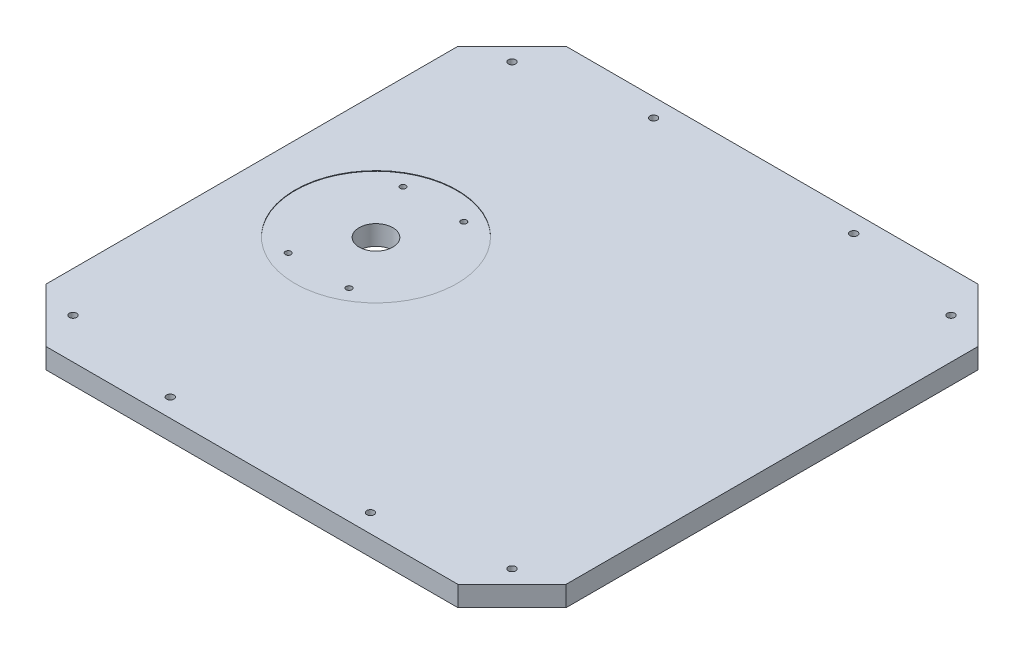
from build123d import *

# Parameters (mm, degrees)
BOSS_EXTRUDE1_DEPTH                = 9.525
F_8_32_TAPPED_HOLE1_D              = 3.4544
F_5_8_0_625_DIAMETER_HOLE1_D       = 15.875
F_6_32_TAPPED_HOLE1_D              = 2.7051
F_6_32_TAPPED_HOLE1_DEPTH          = 8.128
F_6_32_TAPPED_HOLE1_TIP            = 0.81269403
SKETCH8_R                          = 38.1
SKETCH8_R_2                        = 1.35255
SKETCH8_R_3                        = 7.9375
CUT_EXTRUDE1_DEPTH                 = 0.254
F_8_32_TAPPED_HOLE2_D              = 3.4544
F_5_16_0_3125_DIAMETER_HOLE1_D     = 7.9375
F_5_16_0_3125_DIAMETER_HOLE1_DEPTH = 5.08
F_5_16_0_3125_DIAMETER_HOLE1_TIP   = 2.384665582


with BuildPart() as part:
    # Sketch1 → Boss-Extrude1 (new body)
    with BuildSketch(Plane(origin=(0, 0, 0), x_dir=(1, 0, 0), z_dir=(0, 1, 0))):
        Polygon((-96.8375, 122.2375), (-122.2375, 96.8375), (-122.2375, -96.8375), (-96.8375, -122.2375), (96.8375, -122.2375), (122.2375, -96.8375), (122.2375, 96.8375), (96.8375, 122.2375), align=None)
    extrude(amount=BOSS_EXTRUDE1_DEPTH)

    # #8-32 Tapped Hole1 (through all)
    with Locations(Plane(origin=(0, 9.525, 0), x_dir=(1, 0, 0), z_dir=(0, 1, 0))):
        with Locations((-47.0535, 113.6015), (47.0535, 113.6015), (47.0535, -113.6015), (-47.0535, -113.6015)):
            Hole(F_8_32_TAPPED_HOLE1_D / 2)

    # 5/8 (0.625) Diameter Hole1 (through all)
    with Locations(Plane(origin=(0, 9.525, 0), x_dir=(1, 0, 0), z_dir=(0, 1, 0))):
        with Locations((-63.9445, 0)):
            Hole(F_5_8_0_625_DIAMETER_HOLE1_D / 2)

    # #6-32 Tapped Hole1
    with Locations(Plane(origin=(0, 9.525, 0), x_dir=(1, 0, 0), z_dir=(0, 1, 0))):
        with Locations((-78.232, -26.9875), (-49.657, -26.9875), (-49.657, 26.9875), (-78.232, 26.9875)):
            Hole(F_6_32_TAPPED_HOLE1_D / 2, depth=F_6_32_TAPPED_HOLE1_DEPTH)
            with Locations((0, 0, -(F_6_32_TAPPED_HOLE1_DEPTH + F_6_32_TAPPED_HOLE1_TIP / 2))):  # 118° drill point
                Cone(0, F_6_32_TAPPED_HOLE1_D / 2, F_6_32_TAPPED_HOLE1_TIP, mode=Mode.SUBTRACT)

    # Sketch8 → Cut-Extrude1 (cut)
    with BuildSketch(Plane(origin=(0, 9.525, 0), x_dir=(1, 0, 0), z_dir=(0, 1, 0))):
        with Locations(Location((-63.9445, 0, 0), (0, 0, 270))):  # turned: the seam where the file's is
            Circle(SKETCH8_R)
        with Locations(Location((-78.232, -26.9875, 0), (0, 0, 270))):  # turned: the seam where the file's is
            Circle(SKETCH8_R_2, mode=Mode.SUBTRACT)
        with Locations(Location((-49.657, 26.9875, 0), (0, 0, 270))):  # turned: the seam where the file's is
            Circle(SKETCH8_R_2, mode=Mode.SUBTRACT)
        with Locations(Location((-63.9445, 0, 0), (0, 0, 270))):  # turned: the seam where the file's is
            Circle(SKETCH8_R_3, mode=Mode.SUBTRACT)
        with Locations(Location((-78.232, 26.9875, 0), (0, 0, 270))):  # turned: the seam where the file's is
            Circle(SKETCH8_R_2, mode=Mode.SUBTRACT)
        with Locations(Location((-49.657, -26.9875, 0), (0, 0, 270))):  # turned: the seam where the file's is
            Circle(SKETCH8_R_2, mode=Mode.SUBTRACT)
    extrude(amount=-CUT_EXTRUDE1_DEPTH, mode=Mode.SUBTRACT)

    # #8-32 Tapped Hole2 (through all)
    with Locations(Plane(origin=(0, 9.525, 0), x_dir=(1, 0, 0), z_dir=(0, 1, 0))):
        with Locations((-103.1875, 103.1875), (103.1875, 103.1875), (103.1875, -103.1875), (-103.1875, -103.1875)):
            Hole(F_8_32_TAPPED_HOLE2_D / 2)

    # 5/16 (0.3125) Diameter Hole1
    with Locations(Plane(origin=(0, 0, 0), x_dir=(-1, 0, 0), z_dir=(0, -1, 0))):
        with Locations((85.0011, 0), (-85.0011, -52.5145), (-85.0011, 52.4891)):
            Hole(F_5_16_0_3125_DIAMETER_HOLE1_D / 2, depth=F_5_16_0_3125_DIAMETER_HOLE1_DEPTH)
            with Locations((0, 0, -(F_5_16_0_3125_DIAMETER_HOLE1_DEPTH + F_5_16_0_3125_DIAMETER_HOLE1_TIP / 2))):  # 118° drill point
                Cone(0, F_5_16_0_3125_DIAMETER_HOLE1_D / 2, F_5_16_0_3125_DIAMETER_HOLE1_TIP, mode=Mode.SUBTRACT)


solid = part.part
